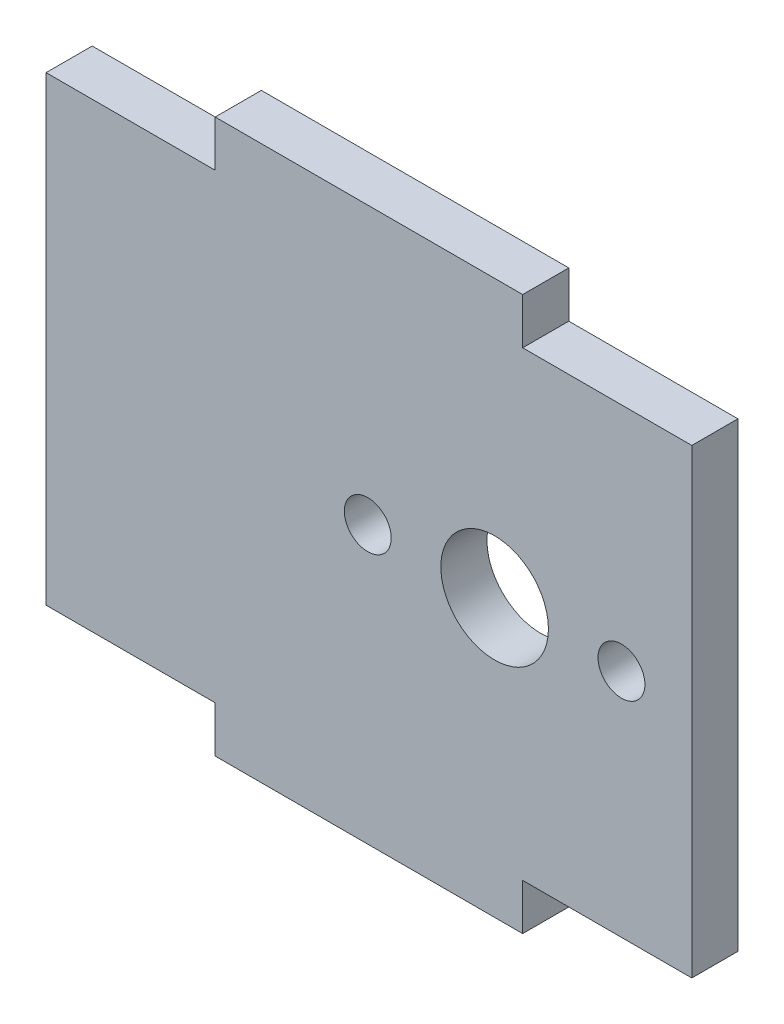
from build123d import *

# Parameters (mm, degrees)
SKETCH1_W           = 42
SKETCH1_H           = 30
SKETCH1_W_2         = 20
SKETCH1_H_2         = 3
BOSS_EXTRUDE1_DEPTH = 3
SKETCH2_R           = 3.5
SKETCH2_R_2         = 1.525
CUT_EXTRUDE1_DEPTH  = 4


with BuildPart() as part:
    # Sketch1 → Boss-Extrude1 (new body)
    with BuildSketch(Plane.XY):
        Rectangle(SKETCH1_W, SKETCH1_H)
        with Locations((0, 16.5)):
            Rectangle(SKETCH1_W_2, SKETCH1_H_2)
        with Locations((0, -16.5)):
            Rectangle(SKETCH1_W_2, SKETCH1_H_2)
    extrude(amount=BOSS_EXTRUDE1_DEPTH)

    # Sketch2 → Cut-Extrude1 (cut, through all)
    with BuildSketch(Plane.XY.offset(3)):
        with Locations((8.175, 0)):
            Circle(SKETCH2_R)
        with Locations((16.425, 0)):
            Circle(SKETCH2_R_2)
        with Locations((-0.075, 0)):
            Circle(SKETCH2_R_2)
    extrude(amount=-CUT_EXTRUDE1_DEPTH, mode=Mode.SUBTRACT)


solid = part.part
